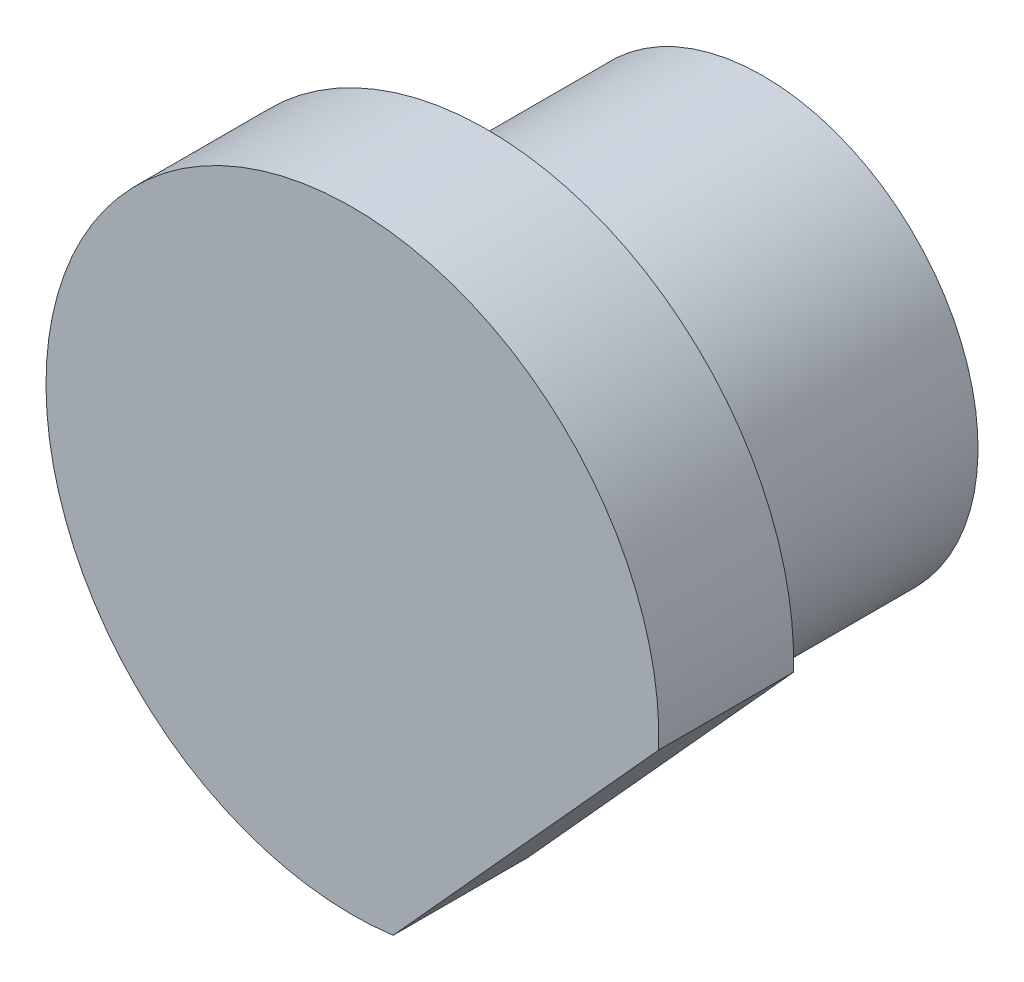
from build123d import *

# Parameters (mm, degrees)
SKETCH_2_R        = 3.501329815
EXTRUDE_1_DEPTH   = 4.491890815
EXTRUDE_2_DEPTH   = 2.193354394
MOVE_BODY_1_ANGLE = 90


with BuildPart() as part:
    # Эскиз2 → Бобышка-Вытянуть1 (new body)
    with BuildSketch(Plane(origin=(0, 0, 0), x_dir=(1, 0, 0), z_dir=(0, 1, 0))):
        Circle(SKETCH_2_R)
    extrude(amount=EXTRUDE_1_DEPTH)

    # Эскиз3 → Бобышка-Вытянуть2 (add)
    with BuildSketch(Plane(origin=(0, 0, 0), x_dir=(-1, 0, 0), z_dir=(0, -1, 0))):
        with BuildLine():
            Line((-0.662486279, 4.945665231), (-4.986919029, 0.170678767))
            ThreePointArc((-4.986919029, 0.170678767), (3.698522545, -3.349540809), (-0.662486279, 4.945665231))
        make_face()
    extrude(amount=EXTRUDE_2_DEPTH)


with BuildPart() as part_1:
    # Move Body 1: moved
    add(part.part.rotate(Axis((0, 1.149268211, 0), (-1, 0, 0)), MOVE_BODY_1_ANGLE))


with BuildPart() as part_2:
    # Move Body 2: moved
    add(part_1.part.moved(Location((0, 0, -3.34))))


solid = part_2.part
